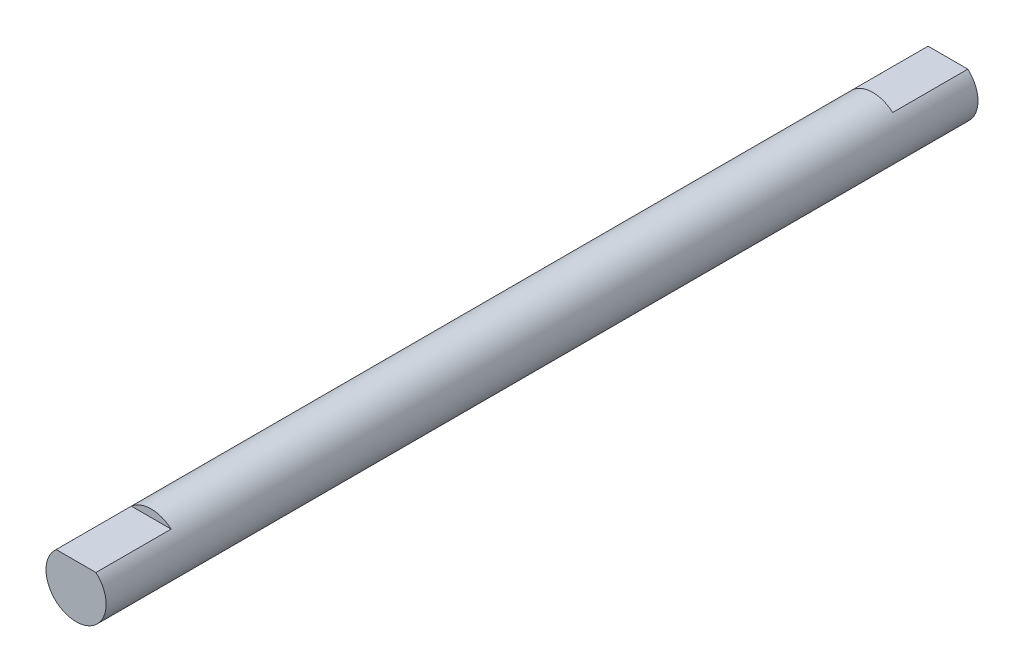
from build123d import *

# Parameters (mm, degrees)
RESSALTO_EXTRUS_O1_DEPTH      = 58
RESSALTO_EXTRUS_O1_DEPTH_BACK = 58
ESBO_O1_R                     = 4
CORTE_EXTRUS_O1_DEPTH         = 10


with BuildPart() as part:
    # Esboço1 → Ressalto-extrusão1 (new, two sides: drawn at the far end of the back side and taken through both)
    with BuildSketch(Plane.XY.offset(-RESSALTO_EXTRUS_O1_DEPTH_BACK)):
        Circle(ESBO_O1_R)
    extrude(amount=RESSALTO_EXTRUS_O1_DEPTH + RESSALTO_EXTRUS_O1_DEPTH_BACK)

    # Esboço2 → Corte-extrusão1 (cut)
    with BuildSketch(Plane.XY.offset(58)):
        with BuildLine():
            Line((2.645751311, 3), (-2.645751311, 3))
            ThreePointArc((-2.645751311, 3), (0, 4), (2.645751311, 3))
        make_face()
    corte_extrus_o1 = extrude(amount=-CORTE_EXTRUS_O1_DEPTH, mode=Mode.SUBTRACT)

    # Espelhar2: Corte-extrusão1 across plane
    add(corte_extrus_o1.mirror(Plane.XY), mode=Mode.SUBTRACT)


solid = part.part
